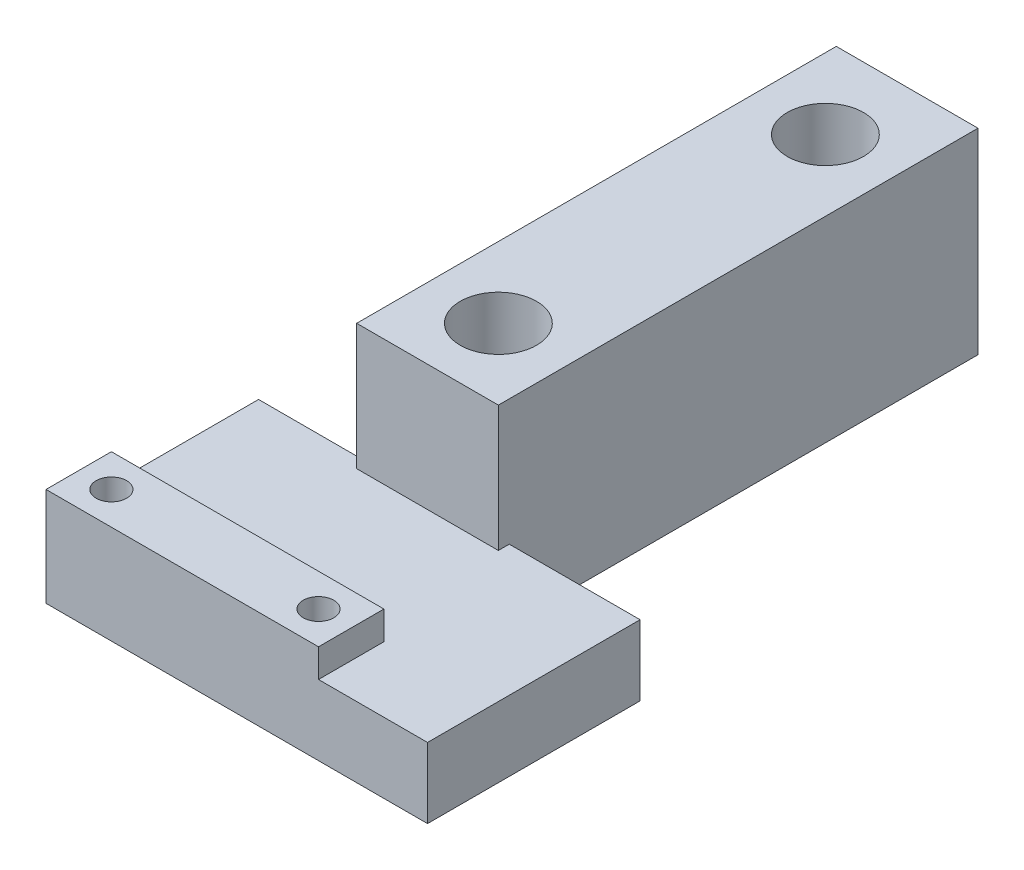
from build123d import *

# Parameters (mm, degrees)
SKETCH1_W           = 35
SKETCH1_H           = 19.5
BOSS_EXTRUDE1_DEPTH = 6.45
SKETCH2_W           = 13
SKETCH2_H           = 44
BOSS_EXTRUDE2_DEPTH = 18
SKETCH3_R           = 3.5
CUT_EXTRUDE1_DEPTH  = 19
SKETCH4_W           = 25
SKETCH4_H           = 6
BOSS_EXTRUDE3_DEPTH = 2.6
SKETCH5_R           = 1.4
CUT_EXTRUDE2_DEPTH  = 10.05


with BuildPart() as part:
    # Sketch1 → Boss-Extrude1 (new body)
    with BuildSketch(Plane(origin=(0, 0, 0), x_dir=(1, 0, 0), z_dir=(0, 1, 0))):
        Rectangle(SKETCH1_W, SKETCH1_H)
    extrude(amount=BOSS_EXTRUDE1_DEPTH)

    # Sketch2 → Boss-Extrude2 (add)
    with BuildSketch(Plane(origin=(0, 0, 0), x_dir=(1, 0, 0), z_dir=(0, 1, 0))):
        with Locations((-1, 30.75)):
            Rectangle(SKETCH2_W, SKETCH2_H)
    extrude(amount=BOSS_EXTRUDE2_DEPTH)

    # Sketch3 → Cut-Extrude1 (cut, through all)
    with BuildSketch(Plane(origin=(0, 18, 0), x_dir=(1, 0, 0), z_dir=(0, 1, 0))):
        with Locations((-1, 45.25)):
            Circle(SKETCH3_R)
        with Locations((-1, 15.25)):
            Circle(SKETCH3_R)
    extrude(amount=-CUT_EXTRUDE1_DEPTH, mode=Mode.SUBTRACT)

    # Sketch4 → Boss-Extrude3 (add)
    with BuildSketch(Plane(origin=(0, 6.45, 0), x_dir=(1, 0, 0), z_dir=(0, 1, 0))):
        with Locations((-5, -6.75)):
            Rectangle(SKETCH4_W, SKETCH4_H)
    extrude(amount=BOSS_EXTRUDE3_DEPTH)

    # Sketch5 → Cut-Extrude2 (cut, through all)
    with BuildSketch(Plane(origin=(0, 9.05, 0), x_dir=(1, 0, 0), z_dir=(0, 1, 0))):
        with Locations((-14.5, -6.75)):
            Circle(SKETCH5_R)
        with Locations((4.5, -6.75)):
            Circle(SKETCH5_R)
    extrude(amount=-CUT_EXTRUDE2_DEPTH, mode=Mode.SUBTRACT)


solid = part.part
